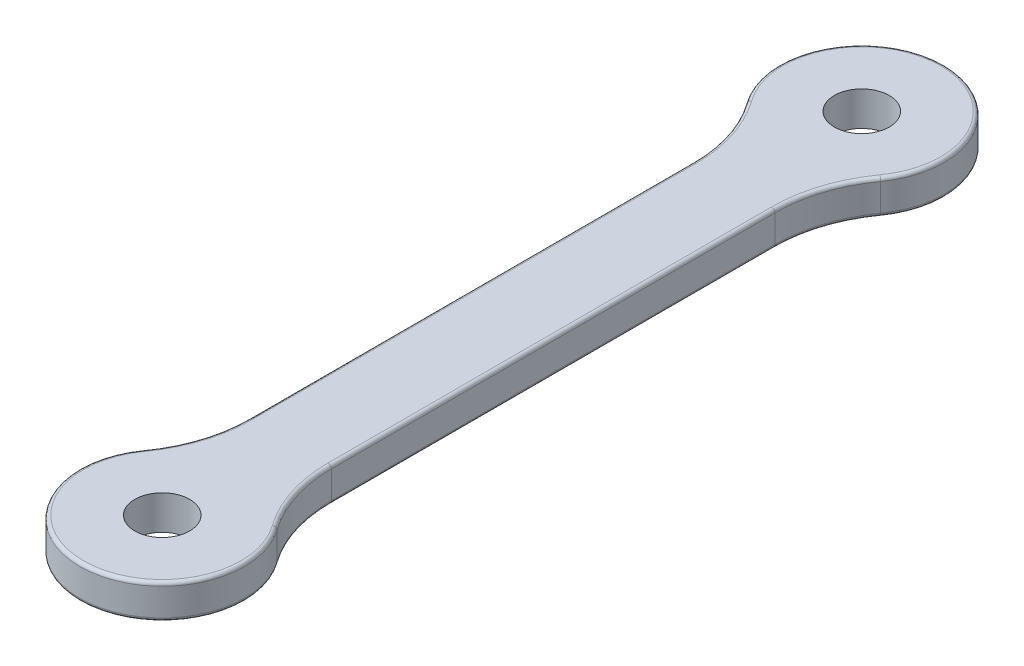
from build123d import *

# Parameters (mm, degrees)
SKETCH1_R           = 2
BOSS_EXTRUDE1_DEPTH = 2.5
FILLET1_R           = 10
FILLET2_R           = 0.25


with BuildPart() as part:
    # Sketch1 → Boss-Extrude1 (new body)
    with BuildSketch(Plane(origin=(0, 0, 0), x_dir=(1, 0, 0), z_dir=(0, 1, 0))):
        with BuildLine():
            ThreePointArc((-3, -20.303847577), (0, -31.5), (3, -20.303847577))
            Line((3, -20.303847577), (3, 20.303847577))
            ThreePointArc((3, 20.303847577), (0, 31.5), (-3, 20.303847577))
            Line((-3, 20.303847577), (-3, -20.303847577))
        make_face()
        with Locations((0, -25.5)):
            Circle(SKETCH1_R, mode=Mode.SUBTRACT)
        with Locations((0, 25.5)):
            Circle(SKETCH1_R, mode=Mode.SUBTRACT)
    extrude(amount=BOSS_EXTRUDE1_DEPTH)

    # Fillet1
    fillet1_edges = [part.edges().sort_by_distance(p)[0] for p in [
        (-3, 1.25, 20.303847577),
        (-3, 1.25, -20.303847577),
        (3, 1.25, -20.303847577),
        (3, 1.25, 20.303847577),
    ]]
    fillet(fillet1_edges, radius=FILLET1_R)

    # Fillet2
    fillet2_edges = [part.edges().sort_by_distance(p)[0] for p in [
        (0, 0, 31.5),
        (0, 2.5, 31.5),
        (-3, 0, 0),
        (-3, 2.5, 0),
        (0, 0, -31.5),
        (0, 2.5, -31.5),
        (3, 0, 0),
        (3, 2.5, 0),
        (-3.480283618, 0, 19.234483125),
        (-3.480283618, 2.5, 19.234483125),
        (-3.480283618, 0, -19.234483125),
        (-3.480283618, 2.5, -19.234483125),
        (3.480283618, 0, -19.234483125),
        (3.480283618, 2.5, -19.234483125),
        (3.480283618, 0, 19.234483125),
        (3.480283618, 2.5, 19.234483125),
    ]]
    fillet(fillet2_edges, radius=FILLET2_R)


solid = part.part
